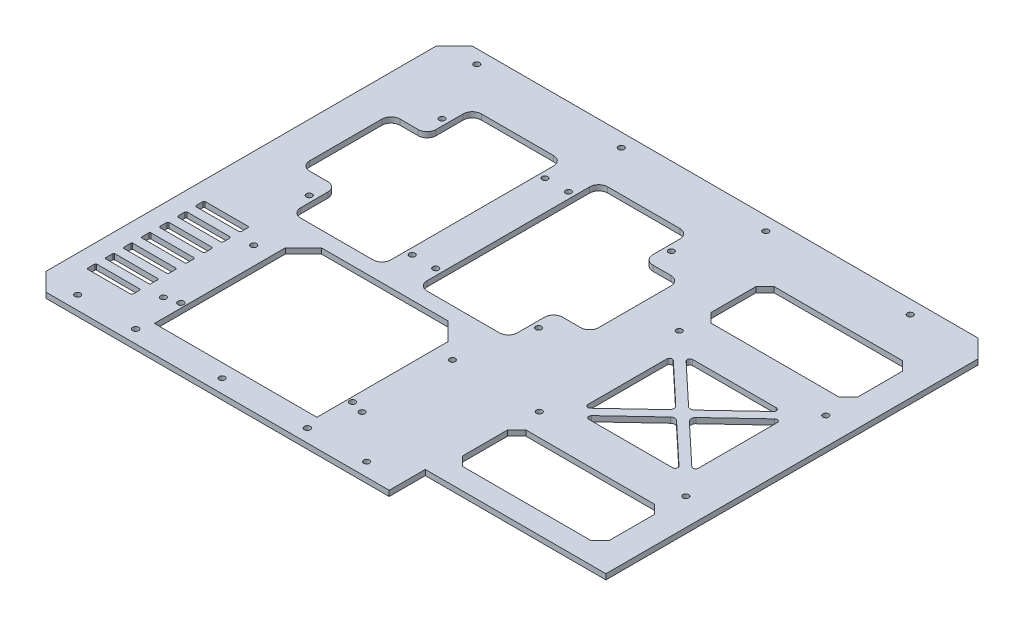
from build123d import *

# Parameters (mm, degrees)
SKETCH_1_W           = 200
SKETCH_1_H           = 236
SKETCH_1_R           = 1.6
EXTRUDE_1_DEPTH      = 3
CUT_EXTRUDE_1_REACH  = 5
SKETCH_2_R           = 1.6
CUT_EXTRUDE_2_REACH  = 5
SKETCH_3_W           = 50
SKETCH_3_H           = 100
CUT_EXTRUDE_3_REACH  = 5
SKETCH_4_W           = 20
SKETCH_4_H           = 50
FILLET_1_R           = 5
CUT_EXTRUDE_4_REACH  = 5
SKETCH_5_R           = 1.6
CUT_EXTRUDE_5_REACH  = 5
CUT_EXTRUDE_6_REACH  = 5
SKETCH_7_W           = 70
SKETCH_7_H           = 75
CUT_EXTRUDE_7_REACH  = 5
SKETCH_8_W           = 70
SKETCH_8_H           = 15
CUT_EXTRUDE_START    = -3
SKETCH_9_W           = 90
SKETCH_9_H           = 82.5
CUT_EXTRUDE_8_DEPTH  = 3
CHAMFER_2_SIZE       = 10
CUT_EXTRUDE_9_REACH  = 5
SKETCH_10_R          = 1.6
CUT_EXTRUDE_10_REACH = 5
SKETCH_12_W          = 236
SKETCH_12_H          = 3
EXTRUDE_2_DEPTH      = 100
SKETCH_13_W          = 20
SKETCH_13_H          = 3
CUT_EXTRUDE_11_DEPTH = 100
CUT_EXTRUDE_12_REACH = 5
SKETCH_14_R          = 1.6
CUT_EXTRUDE_13_REACH = 5
SKETCH_15_W          = 61.15
SKETCH_15_H          = 57.47
EXTRUDE_1_2_DEPTH    = 3
FILLET_2_R           = 1.5
FILLET_3_R           = 2.5
CUT_EXTRUDE_14_REACH = 5
SKETCH_17_W          = 81.15
SKETCH_17_H          = 35
CHAMFER_3_SIZE       = 5
CUT_EXTRUDE_15_REACH = 5
SKETCH_18_R          = 1.6
CHAMFER_4_SIZE       = 10
SKETCH_20_R          = 1.65
CUT_EXTRUDE_16_DEPTH = 10


with BuildPart() as part:
    # 草图1 → Extrude 1 (new body)
    with BuildSketch(Plane(origin=(0, 0, 0), x_dir=(1, 0, 0), z_dir=(0, 1, 0))):
        Rectangle(SKETCH_1_W, SKETCH_1_H)
        with Locations((0, -110.5)):
            Circle(SKETCH_1_R, mode=Mode.SUBTRACT)
        with Locations((-80, -110.5)):
            Circle(SKETCH_1_R, mode=Mode.SUBTRACT)
        with Locations((80, -110.5)):
            Circle(SKETCH_1_R, mode=Mode.SUBTRACT)
        with Locations((80, 110.5)):
            Circle(SKETCH_1_R, mode=Mode.SUBTRACT)
        with Locations((0, 110.5)):
            Circle(SKETCH_1_R, mode=Mode.SUBTRACT)
        with Locations((-80, 110.5)):
            Circle(SKETCH_1_R, mode=Mode.SUBTRACT)
    extrude(amount=EXTRUDE_1_DEPTH)

    # 草图2 → 切除-拉伸1 (cut, up to next)
    with BuildSketch(Plane(origin=(0, 3, 0), x_dir=(1, 0, 0), z_dir=(0, 1, 0)), mode=Mode.PRIVATE) as cut_extrude_1_sk1:
        with Locations((6.5, 74.75)):
            Circle(SKETCH_2_R)
    cut_extrude_1_tool1 = extrude(cut_extrude_1_sk1.sketch, amount=-CUT_EXTRUDE_1_REACH, mode=Mode.PRIVATE) & part.part
    add(cut_extrude_1_tool1.solids().sort_by_distance((6.5, 3, -74.75))[0], mode=Mode.SUBTRACT)
    # 草图2 → 切除-拉伸1 (cut, up to next)
    with BuildSketch(Plane(origin=(0, 3, 0), x_dir=(1, 0, 0), z_dir=(0, 1, 0)), mode=Mode.PRIVATE) as cut_extrude_1_sk2:
        with Locations((63.5, 74.75)):
            Circle(SKETCH_2_R)
    cut_extrude_1_tool2 = extrude(cut_extrude_1_sk2.sketch, amount=-CUT_EXTRUDE_1_REACH, mode=Mode.PRIVATE) & part.part
    add(cut_extrude_1_tool2.solids().sort_by_distance((63.5, 3, -74.75))[0], mode=Mode.SUBTRACT)
    # 草图2 → 切除-拉伸1 (cut, up to next)
    with BuildSketch(Plane(origin=(0, 3, 0), x_dir=(1, 0, 0), z_dir=(0, 1, 0)), mode=Mode.PRIVATE) as cut_extrude_1_sk3:
        with Locations((6.5, 1.25)):
            Circle(SKETCH_2_R)
    cut_extrude_1_tool3 = extrude(cut_extrude_1_sk3.sketch, amount=-CUT_EXTRUDE_1_REACH, mode=Mode.PRIVATE) & part.part
    add(cut_extrude_1_tool3.solids().sort_by_distance((6.5, 3, -1.25))[0], mode=Mode.SUBTRACT)
    # 草图2 → 切除-拉伸1 (cut, up to next)
    with BuildSketch(Plane(origin=(0, 3, 0), x_dir=(1, 0, 0), z_dir=(0, 1, 0)), mode=Mode.PRIVATE) as cut_extrude_1_sk4:
        with Locations((63.5, 1.25)):
            Circle(SKETCH_2_R)
    cut_extrude_1_tool4 = extrude(cut_extrude_1_sk4.sketch, amount=-CUT_EXTRUDE_1_REACH, mode=Mode.PRIVATE) & part.part
    add(cut_extrude_1_tool4.solids().sort_by_distance((63.5, 3, -1.25))[0], mode=Mode.SUBTRACT)
    # 草图2 → 切除-拉伸1 (cut, up to next)
    with BuildSketch(Plane(origin=(0, 3, 0), x_dir=(1, 0, 0), z_dir=(0, 1, 0)), mode=Mode.PRIVATE) as cut_extrude_1_sk5:
        with Locations((-6.5, 74.75)):
            Circle(SKETCH_2_R)
    cut_extrude_1_tool5 = extrude(cut_extrude_1_sk5.sketch, amount=-CUT_EXTRUDE_1_REACH, mode=Mode.PRIVATE) & part.part
    add(cut_extrude_1_tool5.solids().sort_by_distance((-6.5, 3, -74.75))[0], mode=Mode.SUBTRACT)
    # 草图2 → 切除-拉伸1 (cut, up to next)
    with BuildSketch(Plane(origin=(0, 3, 0), x_dir=(1, 0, 0), z_dir=(0, 1, 0)), mode=Mode.PRIVATE) as cut_extrude_1_sk6:
        with Locations((-63.5, 74.75)):
            Circle(SKETCH_2_R)
    cut_extrude_1_tool6 = extrude(cut_extrude_1_sk6.sketch, amount=-CUT_EXTRUDE_1_REACH, mode=Mode.PRIVATE) & part.part
    add(cut_extrude_1_tool6.solids().sort_by_distance((-63.5, 3, -74.75))[0], mode=Mode.SUBTRACT)
    # 草图2 → 切除-拉伸1 (cut, up to next)
    with BuildSketch(Plane(origin=(0, 3, 0), x_dir=(1, 0, 0), z_dir=(0, 1, 0)), mode=Mode.PRIVATE) as cut_extrude_1_sk7:
        with Locations((-63.5, 1.25)):
            Circle(SKETCH_2_R)
    cut_extrude_1_tool7 = extrude(cut_extrude_1_sk7.sketch, amount=-CUT_EXTRUDE_1_REACH, mode=Mode.PRIVATE) & part.part
    add(cut_extrude_1_tool7.solids().sort_by_distance((-63.5, 3, -1.25))[0], mode=Mode.SUBTRACT)
    # 草图2 → 切除-拉伸1 (cut, up to next)
    with BuildSketch(Plane(origin=(0, 3, 0), x_dir=(1, 0, 0), z_dir=(0, 1, 0)), mode=Mode.PRIVATE) as cut_extrude_1_sk8:
        with Locations((-6.5, 1.25)):
            Circle(SKETCH_2_R)
    cut_extrude_1_tool8 = extrude(cut_extrude_1_sk8.sketch, amount=-CUT_EXTRUDE_1_REACH, mode=Mode.PRIVATE) & part.part
    add(cut_extrude_1_tool8.solids().sort_by_distance((-6.5, 3, -1.25))[0], mode=Mode.SUBTRACT)

    # 草图3 → 切除-拉伸2 (cut, up to next)
    with BuildSketch(Plane(origin=(0, 3, 0), x_dir=(1, 0, 0), z_dir=(0, 1, 0)), mode=Mode.PRIVATE) as cut_extrude_2_sk1:
        with Locations((-35, 38)):
            Rectangle(SKETCH_3_W, SKETCH_3_H)
    cut_extrude_2_tool1 = extrude(cut_extrude_2_sk1.sketch, amount=-CUT_EXTRUDE_2_REACH, mode=Mode.PRIVATE) & part.part
    add(cut_extrude_2_tool1.solids().sort_by_distance((-35, 3, -38))[0], mode=Mode.SUBTRACT)
    # 草图3 → 切除-拉伸2 (cut, up to next)
    with BuildSketch(Plane(origin=(0, 3, 0), x_dir=(1, 0, 0), z_dir=(0, 1, 0)), mode=Mode.PRIVATE) as cut_extrude_2_sk2:
        with Locations((35, 38)):
            Rectangle(SKETCH_3_W, SKETCH_3_H)
    cut_extrude_2_tool2 = extrude(cut_extrude_2_sk2.sketch, amount=-CUT_EXTRUDE_2_REACH, mode=Mode.PRIVATE) & part.part
    add(cut_extrude_2_tool2.solids().sort_by_distance((35, 3, -38))[0], mode=Mode.SUBTRACT)

    # 草图4 → 切除-拉伸3 (cut, up to next)
    with BuildSketch(Plane(origin=(0, 3, 0), x_dir=(1, 0, 0), z_dir=(0, 1, 0)), mode=Mode.PRIVATE) as cut_extrude_3_sk1:
        with Locations((-70, 38)):
            Rectangle(SKETCH_4_W, SKETCH_4_H)
    cut_extrude_3_tool1 = extrude(cut_extrude_3_sk1.sketch, amount=-CUT_EXTRUDE_3_REACH, mode=Mode.PRIVATE) & part.part
    add(cut_extrude_3_tool1.solids().sort_by_distance((-70, 3, -38))[0], mode=Mode.SUBTRACT)
    # 草图4 → 切除-拉伸3 (cut, up to next)
    with BuildSketch(Plane(origin=(0, 3, 0), x_dir=(1, 0, 0), z_dir=(0, 1, 0)), mode=Mode.PRIVATE) as cut_extrude_3_sk2:
        with Locations((70, 38)):
            Rectangle(SKETCH_4_W, SKETCH_4_H)
    cut_extrude_3_tool2 = extrude(cut_extrude_3_sk2.sketch, amount=-CUT_EXTRUDE_3_REACH, mode=Mode.PRIVATE) & part.part
    add(cut_extrude_3_tool2.solids().sort_by_distance((70, 3, -38))[0], mode=Mode.SUBTRACT)

    # 圆角1
    fillet_1_edges = [part.edges().sort_by_distance(p)[0] for p in [
        (-60, 1.5, -63),
        (-60, 1.5, -13),
        (-80, 1.5, -13),
        (-80, 1.5, -63),
        (80, 1.5, -63),
        (80, 1.5, -13),
        (60, 1.5, -13),
        (60, 1.5, -63),
        (-10, 1.5, -88),
        (-10, 1.5, 12),
        (-60, 1.5, 12),
        (-60, 1.5, -88),
        (60, 1.5, -88),
        (60, 1.5, 12),
        (10, 1.5, 12),
        (10, 1.5, -88),
    ]]
    fillet(fillet_1_edges, radius=FILLET_1_R)

    # 草图5 → 切除-拉伸4 (cut, up to next)
    with BuildSketch(Plane(origin=(0, 3, 0), x_dir=(1, 0, 0), z_dir=(0, 1, 0)), mode=Mode.PRIVATE) as cut_extrude_4_sk1:
        with Locations((25, -40.5)):
            Circle(SKETCH_5_R)
    cut_extrude_4_tool1 = extrude(cut_extrude_4_sk1.sketch, amount=-CUT_EXTRUDE_4_REACH, mode=Mode.PRIVATE) & part.part
    add(cut_extrude_4_tool1.solids().sort_by_distance((25, 3, 40.5))[0], mode=Mode.SUBTRACT)
    # 草图5 → 切除-拉伸4 (cut, up to next)
    with BuildSketch(Plane(origin=(0, 3, 0), x_dir=(1, 0, 0), z_dir=(0, 1, 0)), mode=Mode.PRIVATE) as cut_extrude_4_sk2:
        with Locations((-25, -40.5)):
            Circle(SKETCH_5_R)
    cut_extrude_4_tool2 = extrude(cut_extrude_4_sk2.sketch, amount=-CUT_EXTRUDE_4_REACH, mode=Mode.PRIVATE) & part.part
    add(cut_extrude_4_tool2.solids().sort_by_distance((-25, 3, 40.5))[0], mode=Mode.SUBTRACT)
    # 草图5 → 切除-拉伸4 (cut, up to next)
    with BuildSketch(Plane(origin=(0, 3, 0), x_dir=(1, 0, 0), z_dir=(0, 1, 0)), mode=Mode.PRIVATE) as cut_extrude_4_sk3:
        with Locations((25, -90.5)):
            Circle(SKETCH_5_R)
    cut_extrude_4_tool3 = extrude(cut_extrude_4_sk3.sketch, amount=-CUT_EXTRUDE_4_REACH, mode=Mode.PRIVATE) & part.part
    add(cut_extrude_4_tool3.solids().sort_by_distance((25, 3, 90.5))[0], mode=Mode.SUBTRACT)
    # 草图5 → 切除-拉伸4 (cut, up to next)
    with BuildSketch(Plane(origin=(0, 3, 0), x_dir=(1, 0, 0), z_dir=(0, 1, 0)), mode=Mode.PRIVATE) as cut_extrude_4_sk4:
        with Locations((-25, -90.5)):
            Circle(SKETCH_5_R)
    cut_extrude_4_tool4 = extrude(cut_extrude_4_sk4.sketch, amount=-CUT_EXTRUDE_4_REACH, mode=Mode.PRIVATE) & part.part
    add(cut_extrude_4_tool4.solids().sort_by_distance((-25, 3, 90.5))[0], mode=Mode.SUBTRACT)

    # 草图6 → 切除-拉伸5 (cut, up to next)
    with BuildSketch(Plane(origin=(0, 3, 0), x_dir=(1, 0, 0), z_dir=(0, 1, 0)), mode=Mode.PRIVATE) as cut_extrude_5_sk1:
        with BuildLine():
            Line((-22.5, -52.571067812), (-22.5, -78.428932188))
            ThreePointArc((-22.5, -78.428932188), (-20.956708581, -80.738631019), (-18.232233047, -80.196699141))
            Line((-18.232233047, -80.196699141), (-5.303300859, -67.267766953))
            ThreePointArc((-5.303300859, -67.267766953), (-4.571067812, -65.5), (-5.303300859, -63.732233047))
            Line((-5.303300859, -63.732233047), (-18.232233047, -50.803300859))
            ThreePointArc((-18.232233047, -50.803300859), (-20.956708581, -50.261368981), (-22.5, -52.571067812))
        make_face()
    cut_extrude_5_tool1 = extrude(cut_extrude_5_sk1.sketch, amount=-CUT_EXTRUDE_5_REACH, mode=Mode.PRIVATE) & part.part
    add(cut_extrude_5_tool1.solids().sort_by_distance((-15.990053, 3, 65.5))[0], mode=Mode.SUBTRACT)
    # 草图6 → 切除-拉伸5 (cut, up to next)
    with BuildSketch(Plane(origin=(0, 3, 0), x_dir=(1, 0, 0), z_dir=(0, 1, 0)), mode=Mode.PRIVATE) as cut_extrude_5_sk2:
        with BuildLine():
            Line((12.928932188, -43), (-12.928932188, -43))
            ThreePointArc((-12.928932188, -43), (-15.238631019, -44.543291419), (-14.696699141, -47.267766953))
            Line((-14.696699141, -47.267766953), (-1.767766953, -60.196699141))
            ThreePointArc((-1.767766953, -60.196699141), (0, -60.928932188), (1.767766953, -60.196699141))
            Line((1.767766953, -60.196699141), (14.696699141, -47.267766953))
            ThreePointArc((14.696699141, -47.267766953), (15.238631019, -44.543291419), (12.928932188, -43))
        make_face()
    cut_extrude_5_tool2 = extrude(cut_extrude_5_sk2.sketch, amount=-CUT_EXTRUDE_5_REACH, mode=Mode.PRIVATE) & part.part
    add(cut_extrude_5_tool2.solids().sort_by_distance((0, 3, 49.509947))[0], mode=Mode.SUBTRACT)
    # 草图6 → 切除-拉伸5 (cut, up to next)
    with BuildSketch(Plane(origin=(0, 3, 0), x_dir=(1, 0, 0), z_dir=(0, 1, 0)), mode=Mode.PRIVATE) as cut_extrude_5_sk3:
        with BuildLine():
            Line((22.5, -78.428932188), (22.5, -52.571067812))
            ThreePointArc((22.5, -52.571067812), (20.956708581, -50.261368981), (18.232233047, -50.803300859))
            Line((18.232233047, -50.803300859), (5.303300859, -63.732233047))
            ThreePointArc((5.303300859, -63.732233047), (4.571067812, -65.5), (5.303300859, -67.267766953))
            Line((5.303300859, -67.267766953), (18.232233047, -80.196699141))
            ThreePointArc((18.232233047, -80.196699141), (20.956708581, -80.738631019), (22.5, -78.428932188))
        make_face()
    cut_extrude_5_tool3 = extrude(cut_extrude_5_sk3.sketch, amount=-CUT_EXTRUDE_5_REACH, mode=Mode.PRIVATE) & part.part
    add(cut_extrude_5_tool3.solids().sort_by_distance((15.990053, 3, 65.5))[0], mode=Mode.SUBTRACT)
    # 草图6 → 切除-拉伸5 (cut, up to next)
    with BuildSketch(Plane(origin=(0, 3, 0), x_dir=(1, 0, 0), z_dir=(0, 1, 0)), mode=Mode.PRIVATE) as cut_extrude_5_sk4:
        with BuildLine():
            Line((-12.928932188, -88), (12.928932188, -88))
            ThreePointArc((12.928932188, -88), (15.238631019, -86.456708581), (14.696699141, -83.732233047))
            Line((14.696699141, -83.732233047), (1.767766953, -70.803300859))
            ThreePointArc((1.767766953, -70.803300859), (0, -70.071067812), (-1.767766953, -70.803300859))
            Line((-1.767766953, -70.803300859), (-14.696699141, -83.732233047))
            ThreePointArc((-14.696699141, -83.732233047), (-15.238631019, -86.456708581), (-12.928932188, -88))
        make_face()
    cut_extrude_5_tool4 = extrude(cut_extrude_5_sk4.sketch, amount=-CUT_EXTRUDE_5_REACH, mode=Mode.PRIVATE) & part.part
    add(cut_extrude_5_tool4.solids().sort_by_distance((0, 3, 81.490053))[0], mode=Mode.SUBTRACT)

    # 草图7 → 切除-拉伸6 (cut, up to next)
    with BuildSketch(Plane(origin=(0, 3, 0), x_dir=(1, 0, 0), z_dir=(0, 1, 0)), mode=Mode.PRIVATE) as cut_extrude_6_sk1:
        with Locations((0, -65.5)):
            Rectangle(SKETCH_7_W, SKETCH_7_H)
    cut_extrude_6_tool1 = extrude(cut_extrude_6_sk1.sketch, amount=-CUT_EXTRUDE_6_REACH, mode=Mode.PRIVATE) & part.part
    add(cut_extrude_6_tool1.solids().sort_by_distance((0, 3, 65.5))[0], mode=Mode.SUBTRACT)

    # 草图8 → 切除-拉伸7 (cut, up to next)
    with BuildSketch(Plane(origin=(0, 3, 0), x_dir=(1, 0, 0), z_dir=(0, 1, 0)), mode=Mode.PRIVATE) as cut_extrude_7_sk1:
        with Locations((0, -28)):
            Rectangle(SKETCH_8_W, SKETCH_8_H)
    cut_extrude_7_tool1 = extrude(cut_extrude_7_sk1.sketch, amount=-CUT_EXTRUDE_7_REACH, mode=Mode.PRIVATE) & part.part
    add(cut_extrude_7_tool1.solids().sort_by_distance((0, 3, 28))[0], mode=Mode.SUBTRACT)

    # 草图9 → 切除-拉伸8 (cut)
    with BuildSketch(Plane(origin=(0, 3, 0), x_dir=(1, 0, 0), z_dir=(0, 1, 0)).offset(CUT_EXTRUDE_START)):
        with Locations((0, -61.75)):
            Rectangle(SKETCH_9_W, SKETCH_9_H)
    extrude(amount=CUT_EXTRUDE_8_DEPTH, mode=Mode.SUBTRACT)

    # 倒角2
    chamfer_2_edges = [part.edges().sort_by_distance(p)[0] for p in [
        (-45, 1.5, 20.5),
        (45, 1.5, 20.5),
    ]]
    chamfer(chamfer_2_edges, length=CHAMFER_2_SIZE)

    # 草图10 → 切除-拉伸9 (cut, up to next)
    with BuildSketch(Plane(origin=(0, 3, 0), x_dir=(1, 0, 0), z_dir=(0, 1, 0)), mode=Mode.PRIVATE) as cut_extrude_9_sk1:
        with Locations((55, -38)):
            Circle(SKETCH_10_R)
    cut_extrude_9_tool1 = extrude(cut_extrude_9_sk1.sketch, amount=-CUT_EXTRUDE_9_REACH, mode=Mode.PRIVATE) & part.part
    add(cut_extrude_9_tool1.solids().sort_by_distance((55, 3, 38))[0], mode=Mode.SUBTRACT)
    # 草图10 → 切除-拉伸9 (cut, up to next)
    with BuildSketch(Plane(origin=(0, 3, 0), x_dir=(1, 0, 0), z_dir=(0, 1, 0)), mode=Mode.PRIVATE) as cut_extrude_9_sk2:
        with Locations((55, -88)):
            Circle(SKETCH_10_R)
    cut_extrude_9_tool2 = extrude(cut_extrude_9_sk2.sketch, amount=-CUT_EXTRUDE_9_REACH, mode=Mode.PRIVATE) & part.part
    add(cut_extrude_9_tool2.solids().sort_by_distance((55, 3, 88))[0], mode=Mode.SUBTRACT)
    # 草图10 → 切除-拉伸9 (cut, up to next)
    with BuildSketch(Plane(origin=(0, 3, 0), x_dir=(1, 0, 0), z_dir=(0, 1, 0)), mode=Mode.PRIVATE) as cut_extrude_9_sk3:
        with Locations((-55, -88)):
            Circle(SKETCH_10_R)
    cut_extrude_9_tool3 = extrude(cut_extrude_9_sk3.sketch, amount=-CUT_EXTRUDE_9_REACH, mode=Mode.PRIVATE) & part.part
    add(cut_extrude_9_tool3.solids().sort_by_distance((-55, 3, 88))[0], mode=Mode.SUBTRACT)
    # 草图10 → 切除-拉伸9 (cut, up to next)
    with BuildSketch(Plane(origin=(0, 3, 0), x_dir=(1, 0, 0), z_dir=(0, 1, 0)), mode=Mode.PRIVATE) as cut_extrude_9_sk4:
        with Locations((-55, -38)):
            Circle(SKETCH_10_R)
    cut_extrude_9_tool4 = extrude(cut_extrude_9_sk4.sketch, amount=-CUT_EXTRUDE_9_REACH, mode=Mode.PRIVATE) & part.part
    add(cut_extrude_9_tool4.solids().sort_by_distance((-55, 3, 38))[0], mode=Mode.SUBTRACT)

    # 草图11 → 切除-拉伸10 (cut, up to next)
    with BuildSketch(Plane(origin=(0, 3, 0), x_dir=(1, 0, 0), z_dir=(0, 1, 0)), mode=Mode.PRIVATE) as cut_extrude_10_sk1:
        Polygon((-89.5, -60.5), (-90, -61), (-90, -65), (-89.5, -65.5), (-65.5, -65.5), (-65, -65), (-65, -61), (-65.5, -60.5), align=None)
    cut_extrude_10_tool1 = extrude(cut_extrude_10_sk1.sketch, amount=-CUT_EXTRUDE_10_REACH, mode=Mode.PRIVATE) & part.part
    add(cut_extrude_10_tool1.solids().sort_by_distance((-77.5, 3, 63))[0], mode=Mode.SUBTRACT)
    # 草图11 → 切除-拉伸10 (cut, up to next)
    with BuildSketch(Plane(origin=(0, 3, 0), x_dir=(1, 0, 0), z_dir=(0, 1, 0)), mode=Mode.PRIVATE) as cut_extrude_10_sk2:
        Polygon((-90, -71), (-90, -75), (-89.5, -75.5), (-65.5, -75.5), (-65, -75), (-65, -71), (-65.5, -70.5), (-89.5, -70.5), align=None)
    cut_extrude_10_tool2 = extrude(cut_extrude_10_sk2.sketch, amount=-CUT_EXTRUDE_10_REACH, mode=Mode.PRIVATE) & part.part
    add(cut_extrude_10_tool2.solids().sort_by_distance((-77.5, 3, 73))[0], mode=Mode.SUBTRACT)
    # 草图11 → 切除-拉伸10 (cut, up to next)
    with BuildSketch(Plane(origin=(0, 3, 0), x_dir=(1, 0, 0), z_dir=(0, 1, 0)), mode=Mode.PRIVATE) as cut_extrude_10_sk3:
        Polygon((-90, -81), (-90, -85), (-89.5, -85.5), (-65.5, -85.5), (-65, -85), (-65, -81), (-65.5, -80.5), (-89.5, -80.5), align=None)
    cut_extrude_10_tool3 = extrude(cut_extrude_10_sk3.sketch, amount=-CUT_EXTRUDE_10_REACH, mode=Mode.PRIVATE) & part.part
    add(cut_extrude_10_tool3.solids().sort_by_distance((-77.5, 3, 83))[0], mode=Mode.SUBTRACT)
    # 草图11 → 切除-拉伸10 (cut, up to next)
    with BuildSketch(Plane(origin=(0, 3, 0), x_dir=(1, 0, 0), z_dir=(0, 1, 0)), mode=Mode.PRIVATE) as cut_extrude_10_sk4:
        Polygon((-90, -91), (-90, -95), (-89.5, -95.5), (-65.5, -95.5), (-65, -95), (-65, -91), (-65.5, -90.5), (-89.5, -90.5), align=None)
    cut_extrude_10_tool4 = extrude(cut_extrude_10_sk4.sketch, amount=-CUT_EXTRUDE_10_REACH, mode=Mode.PRIVATE) & part.part
    add(cut_extrude_10_tool4.solids().sort_by_distance((-77.5, 3, 93))[0], mode=Mode.SUBTRACT)
    # 草图11 → 切除-拉伸10 (cut, up to next)
    with BuildSketch(Plane(origin=(0, 3, 0), x_dir=(1, 0, 0), z_dir=(0, 1, 0)), mode=Mode.PRIVATE) as cut_extrude_10_sk5:
        Polygon((-90, -31), (-89.5, -30.5), (-65.5, -30.5), (-65, -31), (-65, -35), (-65.5, -35.5), (-89.5, -35.5), (-90, -35), align=None)
    cut_extrude_10_tool5 = extrude(cut_extrude_10_sk5.sketch, amount=-CUT_EXTRUDE_10_REACH, mode=Mode.PRIVATE) & part.part
    add(cut_extrude_10_tool5.solids().sort_by_distance((-77.5, 3, 33))[0], mode=Mode.SUBTRACT)
    # 草图11 → 切除-拉伸10 (cut, up to next)
    with BuildSketch(Plane(origin=(0, 3, 0), x_dir=(1, 0, 0), z_dir=(0, 1, 0)), mode=Mode.PRIVATE) as cut_extrude_10_sk6:
        Polygon((-90, -41), (-89.5, -40.5), (-65.5, -40.5), (-65, -41), (-65, -45), (-65.5, -45.5), (-89.5, -45.5), (-90, -45), align=None)
    cut_extrude_10_tool6 = extrude(cut_extrude_10_sk6.sketch, amount=-CUT_EXTRUDE_10_REACH, mode=Mode.PRIVATE) & part.part
    add(cut_extrude_10_tool6.solids().sort_by_distance((-77.5, 3, 43))[0], mode=Mode.SUBTRACT)
    # 草图11 → 切除-拉伸10 (cut, up to next)
    with BuildSketch(Plane(origin=(0, 3, 0), x_dir=(1, 0, 0), z_dir=(0, 1, 0)), mode=Mode.PRIVATE) as cut_extrude_10_sk7:
        Polygon((-90, -51), (-89.5, -50.5), (-65.5, -50.5), (-65, -51), (-65, -55), (-65.5, -55.5), (-89.5, -55.5), (-90, -55), align=None)
    cut_extrude_10_tool7 = extrude(cut_extrude_10_sk7.sketch, amount=-CUT_EXTRUDE_10_REACH, mode=Mode.PRIVATE) & part.part
    add(cut_extrude_10_tool7.solids().sort_by_distance((-77.5, 3, 53))[0], mode=Mode.SUBTRACT)

    # 草图12 → 凸台-拉伸2 (add)
    with BuildSketch(Plane(origin=(100, 0, 0), x_dir=(0, 0, -1), z_dir=(1, 0, 0))):
        with Locations((0, 1.5)):
            Rectangle(SKETCH_12_W, SKETCH_12_H)
    extrude(amount=EXTRUDE_2_DEPTH)

    # 草图13 → 切除-拉伸11 (cut)
    with BuildSketch(Plane(origin=(200, 0, 0), x_dir=(0, 0, -1), z_dir=(1, 0, 0))):
        with Locations((-108, 1.5)):
            Rectangle(SKETCH_13_W, SKETCH_13_H)
    extrude(amount=-CUT_EXTRUDE_11_DEPTH, mode=Mode.SUBTRACT)

    # 草图14 → 切除-拉伸12 (cut, up to next)
    with BuildSketch(Plane(origin=(0, 3, 0), x_dir=(1, 0, 0), z_dir=(0, 1, 0)), mode=Mode.PRIVATE) as cut_extrude_12_sk1:
        with Locations((103.85, 38.735)):
            Circle(SKETCH_14_R)
    cut_extrude_12_tool1 = extrude(cut_extrude_12_sk1.sketch, amount=-CUT_EXTRUDE_12_REACH, mode=Mode.PRIVATE) & part.part
    add(cut_extrude_12_tool1.solids().sort_by_distance((103.85, 3, -38.735))[0], mode=Mode.SUBTRACT)
    # 草图14 → 切除-拉伸12 (cut, up to next)
    with BuildSketch(Plane(origin=(0, 3, 0), x_dir=(1, 0, 0), z_dir=(0, 1, 0)), mode=Mode.PRIVATE) as cut_extrude_12_sk2:
        with Locations((185, 38.735)):
            Circle(SKETCH_14_R)
    cut_extrude_12_tool2 = extrude(cut_extrude_12_sk2.sketch, amount=-CUT_EXTRUDE_12_REACH, mode=Mode.PRIVATE) & part.part
    add(cut_extrude_12_tool2.solids().sort_by_distance((185, 3, -38.735))[0], mode=Mode.SUBTRACT)
    # 草图14 → 切除-拉伸12 (cut, up to next)
    with BuildSketch(Plane(origin=(0, 3, 0), x_dir=(1, 0, 0), z_dir=(0, 1, 0)), mode=Mode.PRIVATE) as cut_extrude_12_sk3:
        with Locations((103.85, -38.735)):
            Circle(SKETCH_14_R)
    cut_extrude_12_tool3 = extrude(cut_extrude_12_sk3.sketch, amount=-CUT_EXTRUDE_12_REACH, mode=Mode.PRIVATE) & part.part
    add(cut_extrude_12_tool3.solids().sort_by_distance((103.85, 3, 38.735))[0], mode=Mode.SUBTRACT)
    # 草图14 → 切除-拉伸12 (cut, up to next)
    with BuildSketch(Plane(origin=(0, 3, 0), x_dir=(1, 0, 0), z_dir=(0, 1, 0)), mode=Mode.PRIVATE) as cut_extrude_12_sk4:
        with Locations((185, -38.735)):
            Circle(SKETCH_14_R)
    cut_extrude_12_tool4 = extrude(cut_extrude_12_sk4.sketch, amount=-CUT_EXTRUDE_12_REACH, mode=Mode.PRIVATE) & part.part
    add(cut_extrude_12_tool4.solids().sort_by_distance((185, 3, 38.735))[0], mode=Mode.SUBTRACT)

    # 草图15 → 切除-拉伸13 (cut, up to next)
    with BuildSketch(Plane(origin=(0, 3, 0), x_dir=(1, 0, 0), z_dir=(0, 1, 0)), mode=Mode.PRIVATE) as cut_extrude_13_sk1:
        with Locations((144.425, 0)):
            Rectangle(SKETCH_15_W, SKETCH_15_H)
    cut_extrude_13_tool1 = extrude(cut_extrude_13_sk1.sketch, amount=-CUT_EXTRUDE_13_REACH, mode=Mode.PRIVATE) & part.part
    add(cut_extrude_13_tool1.solids().sort_by_distance((144.425, 3, 0))[0], mode=Mode.SUBTRACT)

    # 草图16 → Extrude 1 2 (add)
    with BuildSketch(Plane(origin=(0, 3, 0), x_dir=(1, 0, 0), z_dir=(0, 1, 0))):
        Polygon((112.137898963, 26.913267298), (173.287898963, -30.556732702), (176.712101037, -26.913267298), (115.562101037, 30.556732702), align=None)
        Polygon((115.562101037, -30.556732702), (176.712101037, 26.913267298), (173.287898963, 30.556732702), (112.137898963, -26.913267298), align=None)
    extrude(amount=-EXTRUDE_1_2_DEPTH)

    # 圆角2
    fillet_2_edges = [part.edges().sort_by_distance(p)[0] for p in [
        (175, 1.5, -25.304200305),
        (175, 1.5, 25.304200305),
        (171.349514506, 1.5, -28.735),
        (117.500485494, 1.5, -28.735),
        (113.85, 1.5, 25.304200305),
        (113.85, 1.5, -25.304200305),
        (117.500485494, 1.5, 28.735),
        (171.349514506, 1.5, 28.735),
    ]]
    fillet(fillet_2_edges, radius=FILLET_2_R)

    # 圆角3
    fillet_3_edges = [part.edges().sort_by_distance(p)[0] for p in [
        (144.425, 1.5, 3.430799695),
        (140.774514506, 1.5, 0),
        (144.425, 1.5, -3.430799695),
        (148.075485494, 1.5, 0),
    ]]
    fillet(fillet_3_edges, radius=FILLET_3_R)

    # 草图17 → 切除-拉伸14 (cut, up to next)
    with BuildSketch(Plane(origin=(0, 3, 0), x_dir=(1, 0, 0), z_dir=(0, 1, 0)), mode=Mode.PRIVATE) as cut_extrude_14_sk1:
        with Locations((144.425, -68.735)):
            Rectangle(SKETCH_17_W, SKETCH_17_H)
    cut_extrude_14_tool1 = extrude(cut_extrude_14_sk1.sketch, amount=-CUT_EXTRUDE_14_REACH, mode=Mode.PRIVATE) & part.part
    add(cut_extrude_14_tool1.solids().sort_by_distance((144.425, 3, 68.735))[0], mode=Mode.SUBTRACT)
    # 草图17 → 切除-拉伸14 (cut, up to next)
    with BuildSketch(Plane(origin=(0, 3, 0), x_dir=(1, 0, 0), z_dir=(0, 1, 0)), mode=Mode.PRIVATE) as cut_extrude_14_sk2:
        with Locations((144.425, 68.735)):
            Rectangle(SKETCH_17_W, SKETCH_17_H)
    cut_extrude_14_tool2 = extrude(cut_extrude_14_sk2.sketch, amount=-CUT_EXTRUDE_14_REACH, mode=Mode.PRIVATE) & part.part
    add(cut_extrude_14_tool2.solids().sort_by_distance((144.425, 3, -68.735))[0], mode=Mode.SUBTRACT)

    # 倒角3
    chamfer_3_edges = [part.edges().sort_by_distance(p)[0] for p in [
        (185, 1.5, 51.235),
        (185, 1.5, 86.235),
        (103.85, 1.5, 86.235),
        (103.85, 1.5, 51.235),
        (103.85, 1.5, -51.235),
        (103.85, 1.5, -86.235),
        (185, 1.5, -86.235),
        (185, 1.5, -51.235),
    ]]
    chamfer(chamfer_3_edges, length=CHAMFER_3_SIZE)

    # 草图18 → 切除-拉伸15 (cut, up to next)
    with BuildSketch(Plane.XZ, mode=Mode.PRIVATE) as cut_extrude_15_sk1:
        with Locations((160, -110.5)):
            Circle(SKETCH_18_R)
    cut_extrude_15_tool1 = extrude(cut_extrude_15_sk1.sketch, amount=-CUT_EXTRUDE_15_REACH, mode=Mode.PRIVATE) & part.part
    add(cut_extrude_15_tool1.solids().sort_by_distance((160, 0, -110.5))[0], mode=Mode.SUBTRACT)

    # 倒角4
    chamfer_4_edges = [part.edges().sort_by_distance(p)[0] for p in [
        (200, 1.5, -118),
        (-100, 1.5, 118),
        (-100, 1.5, -118),
    ]]
    chamfer(chamfer_4_edges, length=CHAMFER_4_SIZE)

    # 草图20 → 切除-拉伸16 (cut)
    with BuildSketch(Plane.XZ):
        with Locations((-47.5, 85.826293853)):
            Circle(SKETCH_20_R)
        with Locations((-47.5, 110.826293853)):
            Circle(SKETCH_20_R)
        with Locations((47.5, 85.826293853)):
            Circle(SKETCH_20_R)
        with Locations((47.5, 110.826293853)):
            Circle(SKETCH_20_R)
    extrude(amount=-CUT_EXTRUDE_16_DEPTH, mode=Mode.SUBTRACT)


solid = part.part
